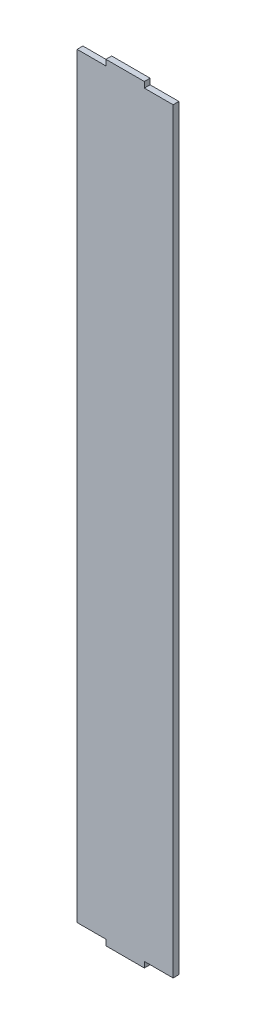
from build123d import *

# Parameters (mm, degrees)
SALIENTE_EXTRUIR3_DEPTH = 3


with BuildPart() as part:
    # Croquis1 → Saliente-Extruir3 (new body)
    with BuildSketch(Plane.XY):
        Polygon((35, -3), (35, 0), (50, 0), (50, 394), (35, 394), (35, 397), (15, 397), (15, 394), (0, 394), (0, 0), (15, 0), (15, -3), align=None)
    extrude(amount=SALIENTE_EXTRUIR3_DEPTH)


solid = part.part
